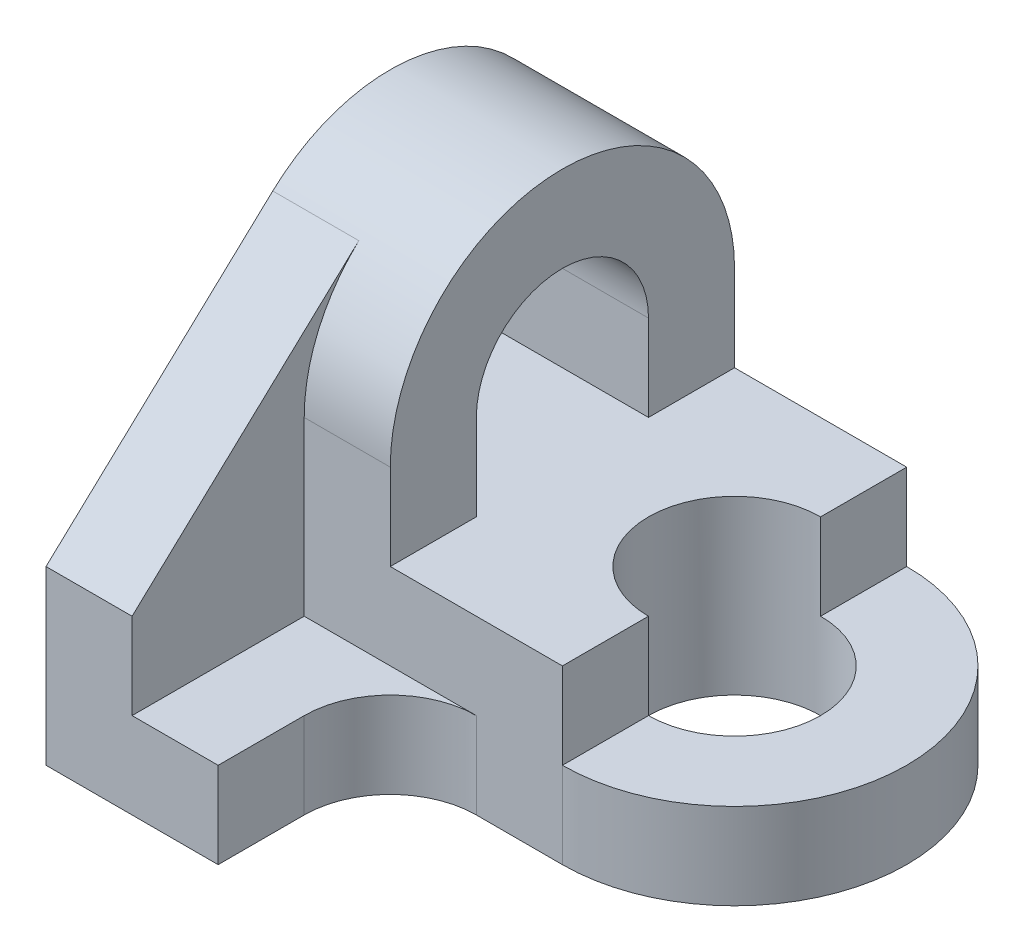
from build123d import *

# Parameters (mm, degrees)
SKETCH1_W           = 4
SKETCH1_H           = 2
BOSS_EXTRUDE1_DEPTH = 4
BOSS_EXTRUDE2_DEPTH = 1
SKETCH3_R           = 1
CUT_EXTRUDE1_DEPTH  = 3
SKETCH4_W           = 2
SKETCH4_H           = 1
BOSS_EXTRUDE3_DEPTH = 2
SKETCH5_W           = 1
SKETCH5_H           = 2
BOSS_EXTRUDE4_DEPTH = 1
BOSS_EXTRUDE5_DEPTH = 1
BOSS_EXTRUDE6_DEPTH = 1


with BuildPart() as part:
    # Sketch1 → Boss-Extrude1 (new body)
    with BuildSketch(Plane.XY):
        Rectangle(SKETCH1_W, SKETCH1_H)
    extrude(amount=BOSS_EXTRUDE1_DEPTH)

    # Sketch2 → Boss-Extrude2 (add)
    with BuildSketch(Plane.XZ.offset(1)):
        with BuildLine():
            Line((2, 4), (2, 0))
            ThreePointArc((2, 0), (4, 2), (2, 4))
        make_face()
    extrude(amount=-BOSS_EXTRUDE2_DEPTH)

    # Sketch3 → Cut-Extrude1 (cut, through all)
    with BuildSketch(Plane(origin=(0, 1, 0), x_dir=(1, 0, 0), z_dir=(0, 1, 0))):
        with Locations((2, -2)):
            Circle(SKETCH3_R)
    extrude(amount=-CUT_EXTRUDE1_DEPTH, mode=Mode.SUBTRACT)

    # Sketch4 → Boss-Extrude3 (add)
    with BuildSketch(Plane.ZY.offset(2)):
        with Locations((5, -0.5)):
            Rectangle(SKETCH4_W, SKETCH4_H)
        with BuildLine():
            Line((0, 1), (0, 2))
            ThreePointArc((0, 2), (2, 4), (4, 2))
            Line((4, 2), (4, 1))
            Line((4, 1), (3, 1))
            Line((3, 1), (3, 2))
            ThreePointArc((3, 2), (2, 3), (1, 2))
            Line((1, 2), (1, 1))
            Line((1, 1), (0, 1))
        make_face()
    extrude(amount=-BOSS_EXTRUDE3_DEPTH)

    # Sketch5 → Boss-Extrude4 (add)
    with BuildSketch(Plane(origin=(0, 0, 0), x_dir=(1, 0, 0), z_dir=(0, 1, 0))):
        with Locations((-1.5, -5)):
            Rectangle(SKETCH5_W, SKETCH5_H)
    extrude(amount=BOSS_EXTRUDE4_DEPTH)

    # Sketch6 → Boss-Extrude5 (add)
    with BuildSketch(Plane.ZY.offset(2)):
        with BuildLine():
            Line((3.365358974, 3.461435894), (6, 1))
            Line((6, 1), (4, 1))
            Line((4, 1), (4, 2))
            ThreePointArc((4, 2), (3.834491475, 2.796643601), (3.365358974, 3.461435894))
        make_face()
    extrude(amount=-BOSS_EXTRUDE5_DEPTH)

    # Sketch7 → Boss-Extrude6 (add)
    with BuildSketch(Plane(origin=(0, 0, 0), x_dir=(1, 0, 0), z_dir=(0, 1, 0))):
        with BuildLine():
            Line((1, -4), (0, -4))
            Line((0, -4), (0, -5))
            ThreePointArc((0, -5), (0.292893219, -4.292893219), (1, -4))
        make_face()
    extrude(amount=-BOSS_EXTRUDE6_DEPTH)


solid = part.part
